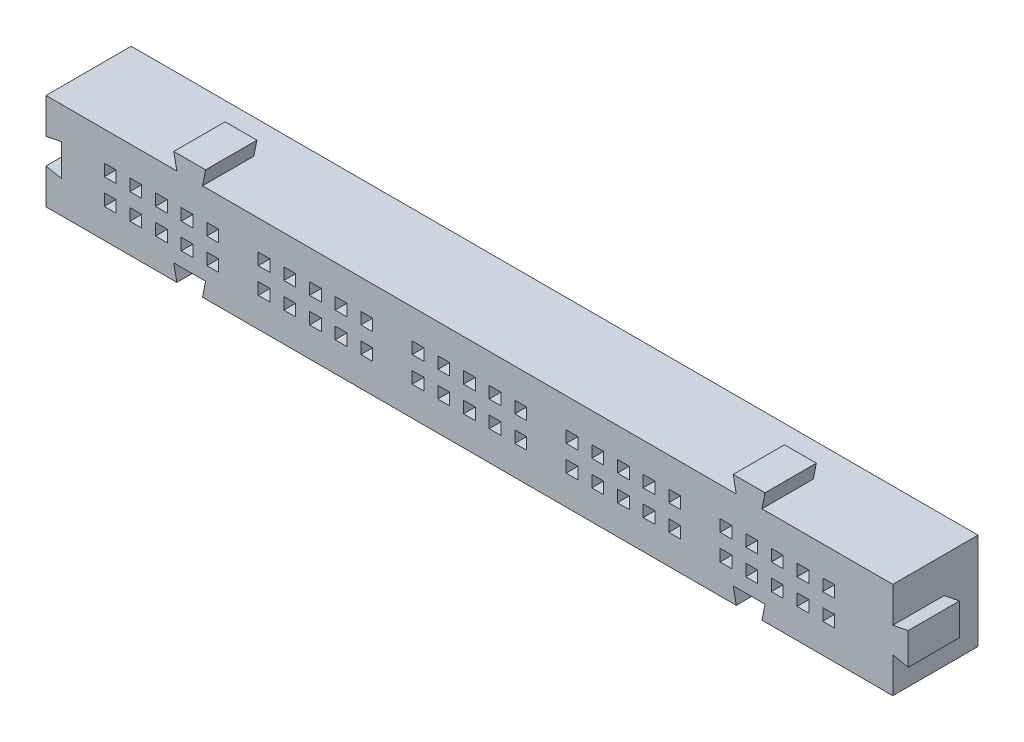
from build123d import *

# Parameters (mm, degrees)
SKIZZE1_W                       = 82.5
SKIZZE1_H                       = 9.4
AUFSATZ_LINEAR_AUSTRAGEN1_DEPTH = 8.3
SKIZZE2_W                       = 2
SKIZZE2_H                       = 2
SCHNITT_LINEAR_AUSTRAGEN1_DEPTH = 2
SCHNITT_LINEAR_AUSTRAGEN1_TAPER = 12
SKIZZE3_W                       = 1.149773754
SKIZZE3_H                       = 1.149773754
SCHNITT_LINEAR_AUSTRAGEN2_DEPTH = 6.3
LINEARES_MUSTER1_COUNT          = 5
LINEARES_MUSTER1_PITCH          = 2.5
LINEARES_MUSTER1_COUNT_DIR2     = 2
LINEARES_MUSTER1_PITCH_DIR2     = 2.5
AUFSATZ_LINEAR_AUSTRAGEN2_DEPTH = 8.3
SKIZZE5_W                       = 86.5
SKIZZE5_H                       = 13.4
SKIZZE5_W_2                     = 82.5
SKIZZE5_H_2                     = 9.4
SCHNITT_LINEAR_AUSTRAGEN3_DEPTH = 3.3
SCHNITT_LINEAR_AUSTRAGEN4_DEPTH = 4.8


with BuildPart() as part:
    # Skizze1 → Aufsatz-Linear austragen1 (new body)
    with BuildSketch(Plane.XY):
        Rectangle(SKIZZE1_W, SKIZZE1_H)
    extrude(amount=AUFSATZ_LINEAR_AUSTRAGEN1_DEPTH)

    # Skizze2 → Schnitt-Linear austragen1 (cut)
    with BuildSketch(Plane(origin=(0, 0, 0), x_dir=(-1, 0, 0), z_dir=(0, 0, -1))):
        with Locations((-35, -1.25)):
            Rectangle(SKIZZE2_W, SKIZZE2_H)
        with Locations((-20, -1.25)):
            Rectangle(SKIZZE2_W, SKIZZE2_H)
        with Locations((-5, -1.25)):
            Rectangle(SKIZZE2_W, SKIZZE2_H)
        with Locations((10, -1.25)):
            Rectangle(SKIZZE2_W, SKIZZE2_H)
        with Locations((25, -1.25)):
            Rectangle(SKIZZE2_W, SKIZZE2_H)
    schnitt_linear_austragen1 = extrude(amount=-SCHNITT_LINEAR_AUSTRAGEN1_DEPTH, taper=SCHNITT_LINEAR_AUSTRAGEN1_TAPER, mode=Mode.SUBTRACT)

    # Skizze3 → Schnitt-Linear austragen2 (cut)
    with BuildSketch(Plane(origin=(0, 0, 2), x_dir=(-1, 0, 0), z_dir=(0, 0, -1))):
        with Locations((-35, -1.25)):
            Rectangle(SKIZZE3_W, SKIZZE3_H)
        with Locations((-20, -1.25)):
            Rectangle(SKIZZE3_W, SKIZZE3_H)
        with Locations((-5, -1.25)):
            Rectangle(SKIZZE3_W, SKIZZE3_H)
        with Locations((10, -1.25)):
            Rectangle(SKIZZE3_W, SKIZZE3_H)
        with Locations((25, -1.25)):
            Rectangle(SKIZZE3_W, SKIZZE3_H)
    schnitt_linear_austragen2 = extrude(amount=-SCHNITT_LINEAR_AUSTRAGEN2_DEPTH, mode=Mode.SUBTRACT)

    # Lineares Muster1: Schnitt-Linear austragen1, Schnitt-Linear austragen2 5 × 2
    with Locations(*[(-i * LINEARES_MUSTER1_PITCH, j * LINEARES_MUSTER1_PITCH_DIR2, 0) for i in range(LINEARES_MUSTER1_COUNT) for j in range(LINEARES_MUSTER1_COUNT_DIR2) if (i, j) != (0, 0)]):
        add(schnitt_linear_austragen1, mode=Mode.SUBTRACT)
        add(schnitt_linear_austragen2, mode=Mode.SUBTRACT)

    # Skizze4 → Aufsatz-Linear austragen2 (add)
    with BuildSketch(Plane(origin=(0, 0, 0), x_dir=(-1, 0, 0), z_dir=(0, 0, -1))):
        Polygon((-26, 4.7), (-25.7, 6.2), (-28.8, 6.2), (-28.5, 4.7), align=None)
        Polygon((28.5, 4.7), (28.8, 6.2), (25.7, 6.2), (26, 4.7), align=None)
        Polygon((-41.25, 1.25), (-42.75, 1.55), (-42.75, -1.55), (-41.25, -1.25), align=None)
    extrude(amount=-AUFSATZ_LINEAR_AUSTRAGEN2_DEPTH)

    # Skizze5 → Schnitt-Linear austragen3 (cut)
    with BuildSketch(Plane(origin=(0, 0, 0), x_dir=(-1, 0, 0), z_dir=(0, 0, -1))):
        Rectangle(SKIZZE5_W, SKIZZE5_H)
        Rectangle(SKIZZE5_W_2, SKIZZE5_H_2, mode=Mode.SUBTRACT)
    extrude(amount=-SCHNITT_LINEAR_AUSTRAGEN3_DEPTH, mode=Mode.SUBTRACT)

    # Skizze6 → Schnitt-Linear austragen4 (cut)
    with BuildSketch(Plane.XY.offset(8.3)):
        Polygon((-41.25, -1.25), (-39.75, -1.55), (-39.75, 1.55), (-41.25, 1.25), align=None)
        Polygon((-26, -4.7), (-25.7, -3.2), (-28.8, -3.2), (-28.5, -4.7), align=None)
        Polygon((28.5, -4.7), (28.8, -3.2), (25.7, -3.2), (26, -4.7), align=None)
    extrude(amount=-SCHNITT_LINEAR_AUSTRAGEN4_DEPTH, mode=Mode.SUBTRACT)


solid = part.part
